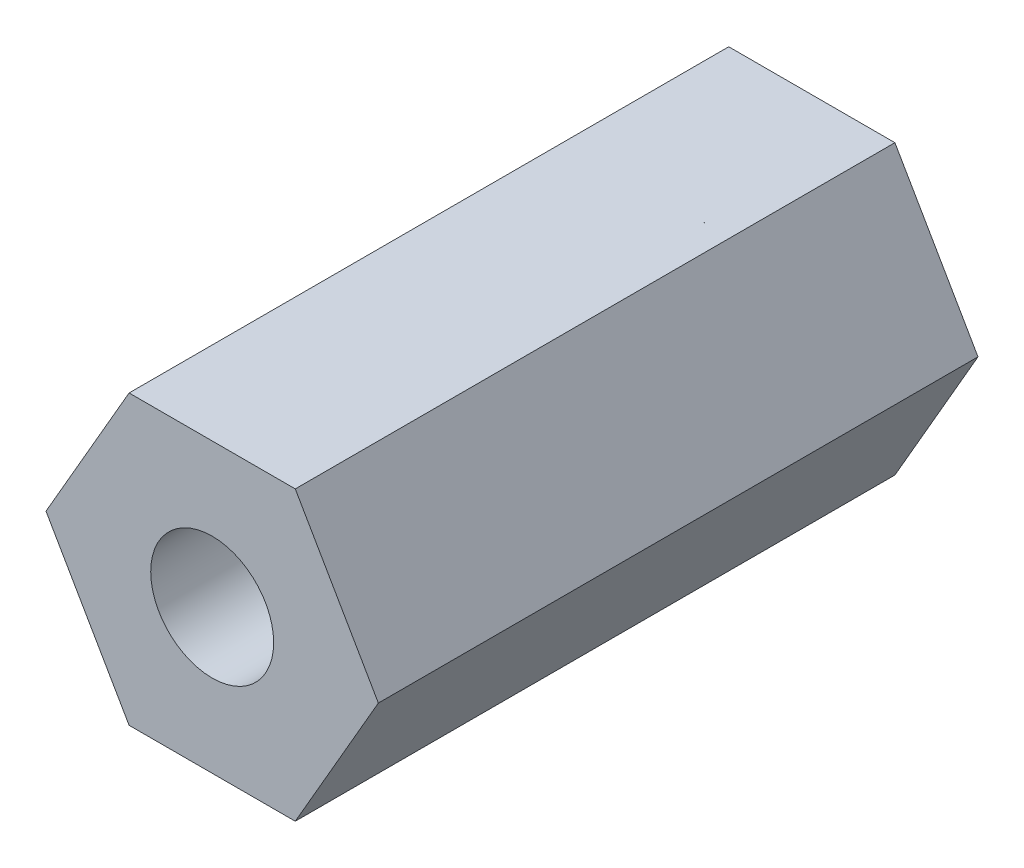
from build123d import *

# Parameters (mm, degrees)
BOSS_EXTRUDE1_DEPTH = 20
SKETCH3_R           = 2.05
CUT_EXTRUDE1_DEPTH  = 20


with BuildPart() as part:
    # Sketch2 → Boss-Extrude1 (new body)
    with BuildSketch(Plane.XY):
        Polygon((5.542562584, 0), (2.771281292, 4.8), (-2.771281292, 4.8), (-5.542562584, 0), (-2.771281292, -4.8), (2.771281292, -4.8), align=None)
    extrude(amount=BOSS_EXTRUDE1_DEPTH)

    # Sketch3 → Cut-Extrude1 (cut)
    with BuildSketch(Plane(origin=(0, 0, 0), x_dir=(-1, 0, 0), z_dir=(0, 0, -1))):
        Circle(SKETCH3_R)
    extrude(amount=-CUT_EXTRUDE1_DEPTH, mode=Mode.SUBTRACT)


solid = part.part
